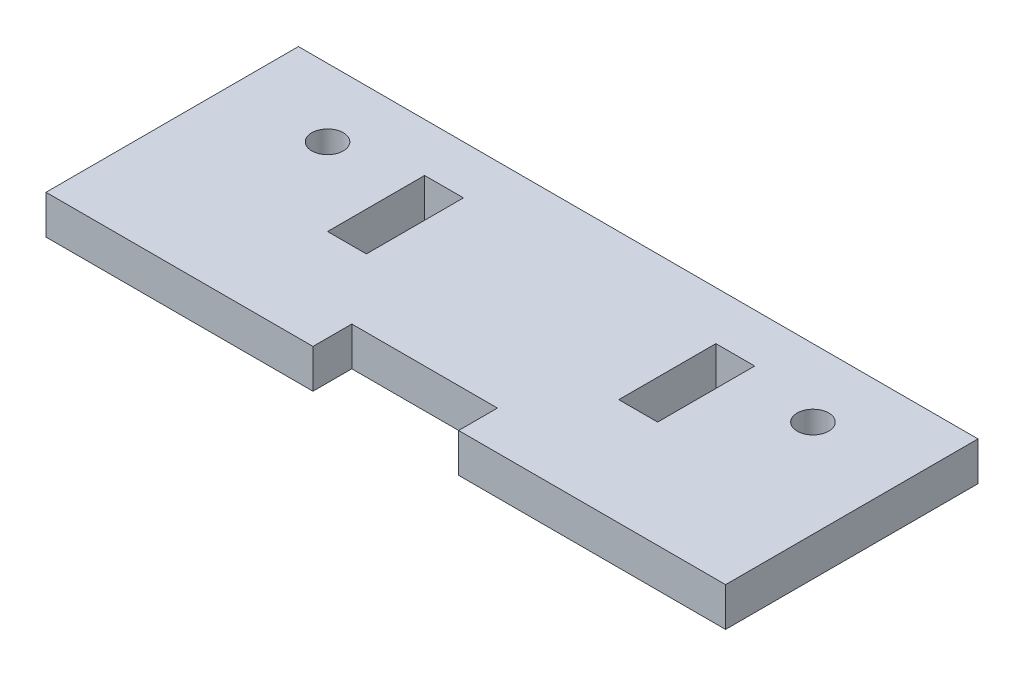
from build123d import *

# Parameters (mm, degrees)
SKETCH1_R           = 1.625
SKETCH1_W           = 4
SKETCH1_H           = 10
BOSS_EXTRUDE1_DEPTH = 4


with BuildPart() as part:
    # Sketch1 → Boss-Extrude1 (new body)
    with BuildSketch(Plane(origin=(0, 0, 0), x_dir=(1, 0, 0), z_dir=(0, 1, 0))):
        Polygon((0, 0), (20, 0), (27.5, 0), (27.5, 4), (42.5, 4), (42.5, 0), (50, 0), (70, 0), (70, 26), (0, 26), align=None)
        with Locations((10, 19)):
            Circle(SKETCH1_R, mode=Mode.SUBTRACT)
        with Locations((60, 19)):
            Circle(SKETCH1_R, mode=Mode.SUBTRACT)
        with Locations((20, 16)):
            Rectangle(SKETCH1_W, SKETCH1_H, mode=Mode.SUBTRACT)
        with Locations((50, 16)):
            Rectangle(SKETCH1_W, SKETCH1_H, mode=Mode.SUBTRACT)
    extrude(amount=BOSS_EXTRUDE1_DEPTH)


solid = part.part
